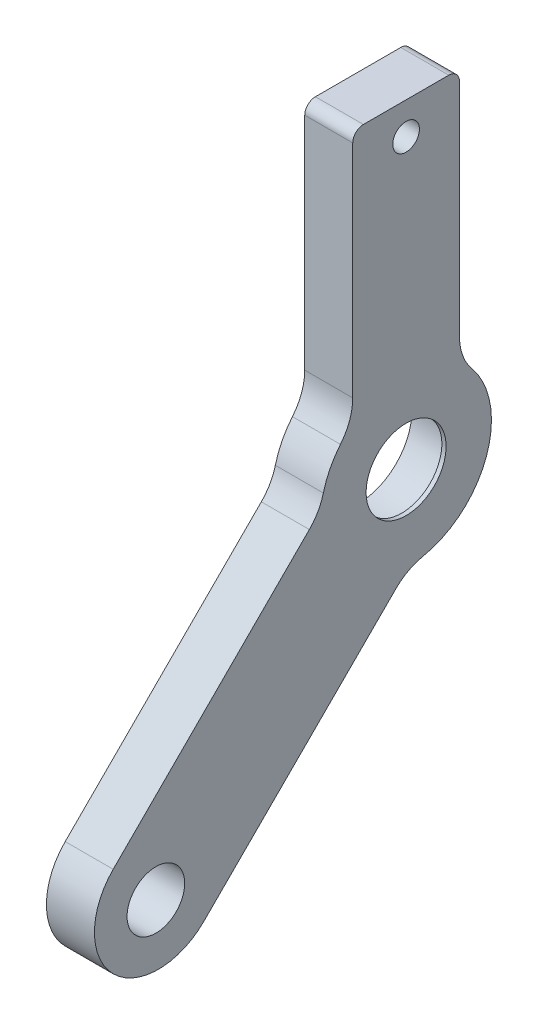
from build123d import *

# Parameters (mm, degrees)
SKETCH_1_R          = 2.7
EXTRUDE_1_DEPTH     = 2.25
SKETCH_4_R          = 3.75
CUT_EXTRUDE_2_DEPTH = 5
SKETCH_7_R          = 5.05
CUT_EXTRUDE_4_DEPTH = 4.1
SKETCH_8_R          = 1.25
CUT_EXTRUDE_5_DEPTH = 6


with BuildPart() as part:
    # 草图1 → 凸台-拉伸1 (new body, symmetric)
    with BuildSketch(Plane.ZY):
        with BuildLine():
            Line((-4, 30), (4, 30))
            ThreePointArc((4, 30), (4.707106781, 29.707106781), (5, 29))
            Line((5, 29), (5, 8.306623863))
            ThreePointArc((5, 8.306623863), (5.297300284, 6.608208312), (6.153846154, 5.111768531))
            ThreePointArc((6.153846154, 5.111768531), (7.130688706, 3.626744901), (7.755507367, 1.962678138))
            ThreePointArc((7.755507367, 1.962678138), (8.255259703, 0.719581246), (9.067165566, -0.346181931))
            Line((9.067165566, -0.346181931), (27.451942184, -18.730958549))
            ThreePointArc((27.451942184, -18.730958549), (27.451942184, -27.216239924), (18.96666081, -27.216239924))
            Line((18.96666081, -27.216239924), (0.956494183, -9.206073297))
            ThreePointArc((0.956494183, -9.206073297), (-0.214644447, -8.335970475), (-1.587101368, -7.840989048))
            ThreePointArc((-1.587101368, -7.840989048), (-7.544802804, -2.660065909), (-6.153846154, 5.111768531))
            ThreePointArc((-6.153846154, 5.111768531), (-5.297300284, 6.608208312), (-5, 8.306623863))
            Line((-5, 8.306623863), (-5, 29))
            ThreePointArc((-5, 29), (-4.707106781, 29.707106781), (-4, 30))
        make_face()
        with Locations((23.452077304, -23.216375043)):
            Circle(SKETCH_1_R, mode=Mode.SUBTRACT)
    extrude(amount=EXTRUDE_1_DEPTH, both=True)

    # 草图4 → 切除-拉伸2 (cut)
    with BuildSketch(Plane.ZY.offset(-2.25)):
        Circle(SKETCH_4_R)
    extrude(amount=CUT_EXTRUDE_2_DEPTH, mode=Mode.SUBTRACT)

    # 草图7 → 切除-拉伸4 (cut)
    with BuildSketch(Plane.ZY.offset(2.25)):
        Circle(SKETCH_7_R)
    extrude(amount=-CUT_EXTRUDE_4_DEPTH, mode=Mode.SUBTRACT)

    # 草图8 → 切除-拉伸5 (cut)
    with BuildSketch(Plane(origin=(2.25, 0, 0), x_dir=(0, 0, -1), z_dir=(1, 0, 0))):
        with Locations((0, 27)):
            Circle(SKETCH_8_R)
    extrude(amount=-CUT_EXTRUDE_5_DEPTH, mode=Mode.SUBTRACT)


solid = part.part
